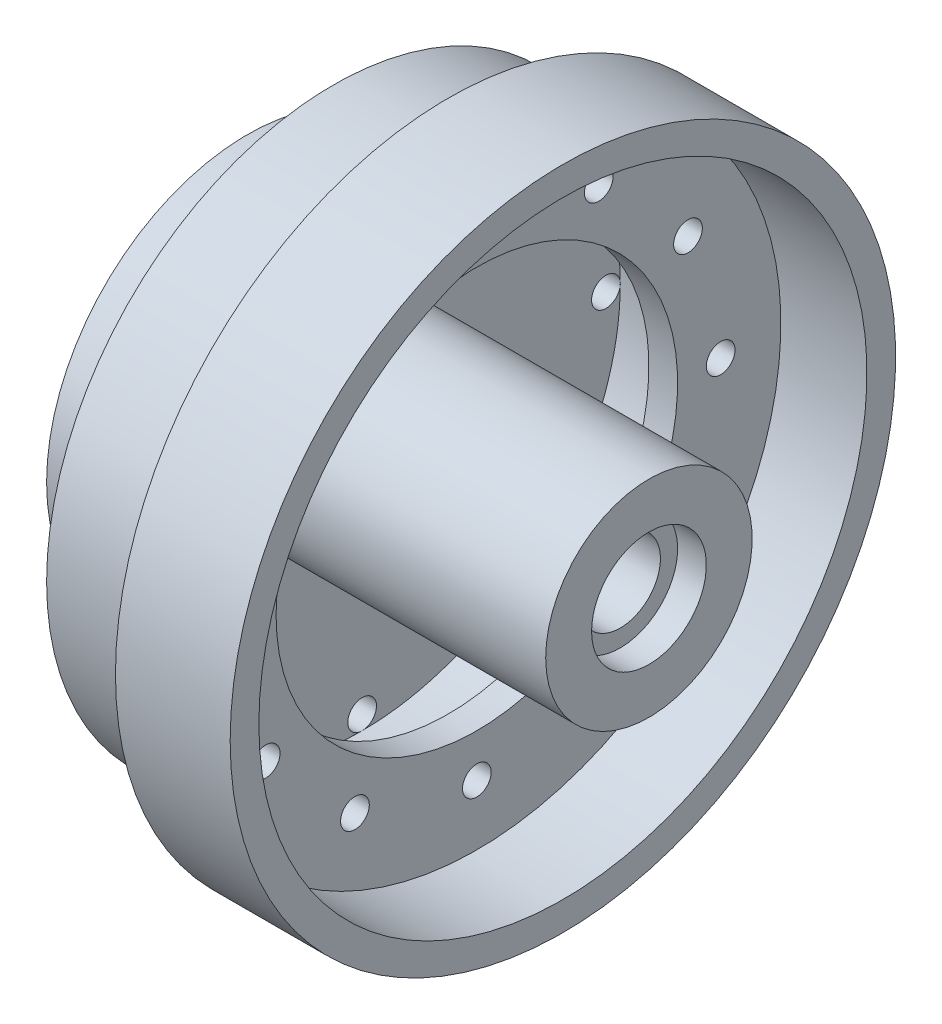
from build123d import *

# Parameters (mm, degrees)
SCHIZZO2_R                  = 2.5
TAGLIO_ESTRUSIONE1_DEPTH    = 56
RIPETIZIONECIRCOLARE1_COUNT = 12


with BuildPart() as part:
    # Schizzo1 → Rivoluzione1 (revolve)
    with BuildSketch(Plane.XY):
        Polygon((-35, 7), (45, 7), (45, 10), (50, 10), (50, 18), (0.0029942, 18), (0.0029942, 45), (15, 45), (15, 35), (20, 35), (20, 53), (35, 53), (35, 58), (15, 58), (15, 50), (-5, 50), (-5, 35), (-20, 35), (-20, 30), (-5, 30), (-5, 18), (-35, 13), align=None)
    revolve(axis=Axis((-44.939802223, 0, 0), (1, 0, 0)))

    # Schizzo2 → Taglio-Estrusione1 (cut, through all)
    with BuildSketch(Plane.ZY.offset(5)):
        with Locations((0, -42.5)):
            Circle(SCHIZZO2_R)
    taglio_estrusione1 = extrude(amount=-TAGLIO_ESTRUSIONE1_DEPTH, mode=Mode.SUBTRACT)

    # RipetizioneCircolare1: Taglio-Estrusione1 ×12 about axis
    ripetizionecircolare1_axis = Axis((0, 0, 0), (1, 0, 0))
    for i in range(1, RIPETIZIONECIRCOLARE1_COUNT):
        add(taglio_estrusione1.rotate(ripetizionecircolare1_axis, i * 360 / RIPETIZIONECIRCOLARE1_COUNT), mode=Mode.SUBTRACT)


solid = part.part
